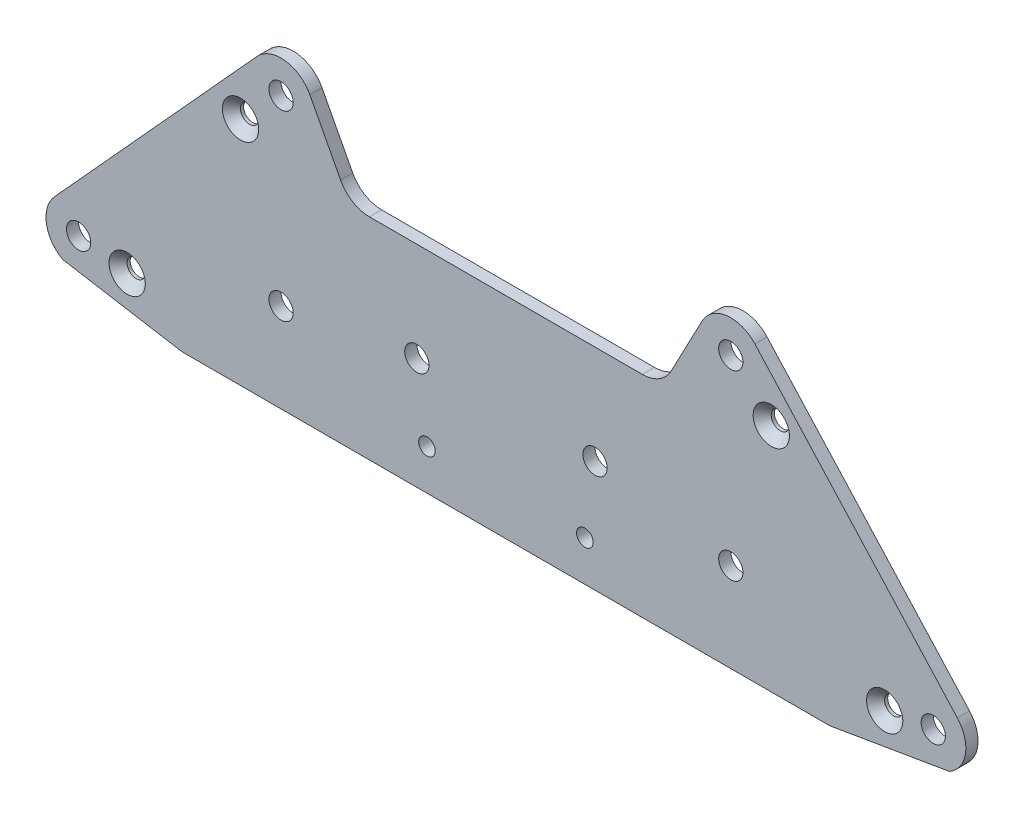
from build123d import *

# Parameters (mm, degrees)
PLATE_DEPTH                  = 3
SKETCH4_R                    = 3
PIVOT_HOLES_ARM_DEPTH        = 4
SKETCH5_R                    = 2.05
CHASSIS_HOLES_DEPTH          = 4
CSK_FOR_M4_SFHCS1_AT_2_COUNT = 2
CSK_FOR_M4_SFHCS1_AT_2_PITCH = 54.708317466
CSK_FOR_M4_SFHCS1_AT_3_COUNT = 2
CSK_FOR_M4_SFHCS1_AT_3_PITCH = 165.871053731
CSK_FOR_M4_SFHCS1_AT_4_COUNT = 2
CSK_FOR_M4_SFHCS1_AT_4_PITCH = 187.072959568


with BuildPart() as part:
    # Sketch2 → Plate (new body)
    with BuildSketch(Plane.XY):
        with BuildLine():
            Line((-80, -12), (80, -12))
            Line((80, -12), (109.503808991, -7))
            ThreePointArc((109.503808991, -7), (113.481492527, -1.271406135), (111.490110497, 5.412391557))
            Line((111.490110497, 5.412391557), (61.490110497, 60.412391557))
            ThreePointArc((61.490110497, 60.412391557), (54.517770463, 62.981349031), (48.414233747, 58.743435912))
            Line((48.414233747, 58.743435912), (40.824196955, 44.302662586))
            ThreePointArc((40.824196955, 44.302662586), (37.862458518, 41.159163218), (33.701950918, 40))
            Line((33.701950918, 40), (-33.701950918, 40))
            ThreePointArc((-33.701950918, 40), (-37.862458518, 41.159163218), (-40.824196955, 44.302662586))
            Line((-40.824196955, 44.302662586), (-48.414233747, 58.743435912))
            ThreePointArc((-48.414233747, 58.743435912), (-54.517770463, 62.981349031), (-61.490110497, 60.412391557))
            Line((-61.490110497, 60.412391557), (-111.490110497, 5.412391557))
            ThreePointArc((-111.490110497, 5.412391557), (-113.481492527, -1.271406135), (-109.503808991, -7))
            Line((-109.503808991, -7), (-80, -12))
        make_face()
    extrude(amount=PLATE_DEPTH)

    # Sketch4 → Pivot holes (arm) (cut, through all)
    with BuildSketch(Plane.XY):
        with Locations((105.536479784, 0)):
            Circle(SKETCH4_R)
        with Locations((55.536479784, 10)):
            Circle(SKETCH4_R)
        with Locations((55.536479784, 55)):
            Circle(SKETCH4_R)
        with Locations((-105.536479784, 0)):
            Circle(SKETCH4_R)
        with Locations((-55.536479784, 10)):
            Circle(SKETCH4_R)
        with Locations((-55.536479784, 55)):
            Circle(SKETCH4_R)
        with Locations((-21.998408138, 15.585494631)):
            Circle(SKETCH4_R)
        with Locations((21.998408138, 15.585494631)):
            Circle(SKETCH4_R)
    extrude(amount=PIVOT_HOLES_ARM_DEPTH, mode=Mode.SUBTRACT)

    # Sketch5 → Chassis holes (cut, through all)
    with BuildSketch(Plane.XY.offset(3)):
        with Locations((-19.5, -2)):
            Circle(SKETCH5_R)
        with Locations((19.5, -2)):
            Circle(SKETCH5_R)
    extrude(amount=-CHASSIS_HOLES_DEPTH, mode=Mode.SUBTRACT)

    # Sketch7 → CSK for M4 SFHCS1 (revolve, cut)
    with BuildSketch(Plane(origin=(93.536479784, -2, 3), x_dir=(0, -1, 0), z_dir=(1, 0, 0))):
        Polygon((0, 0), (0, 3), (2.25, 3), (2.25, 2.23), (4.48, 0), align=None)
    csk_for_m4_sfhcs1 = revolve(axis=Axis((93.536479784, -2, 9.35), (0, 0, -1)), mode=Mode.SUBTRACT)

    # CSK for M4 SFHCS1 at 2: CSK for M4 SFHCS1 ×2
    with Locations(*[Vector(-0.511805175, 0.859101544, 0) * (i * CSK_FOR_M4_SFHCS1_AT_2_PITCH) for i in range(1, CSK_FOR_M4_SFHCS1_AT_2_COUNT)]):
        add(csk_for_m4_sfhcs1, mode=Mode.SUBTRACT)

    # CSK for M4 SFHCS1 at 3: CSK for M4 SFHCS1 ×2
    with Locations(*[Vector(-0.95901579, 0.283352634, 0) * (i * CSK_FOR_M4_SFHCS1_AT_3_PITCH) for i in range(1, CSK_FOR_M4_SFHCS1_AT_3_COUNT)]):
        add(csk_for_m4_sfhcs1, mode=Mode.SUBTRACT)

    # CSK for M4 SFHCS1 at 4: CSK for M4 SFHCS1 ×2
    with Locations(*[(-i * CSK_FOR_M4_SFHCS1_AT_4_PITCH, 0, 0) for i in range(1, CSK_FOR_M4_SFHCS1_AT_4_COUNT)]):
        add(csk_for_m4_sfhcs1, mode=Mode.SUBTRACT)


solid = part.part
